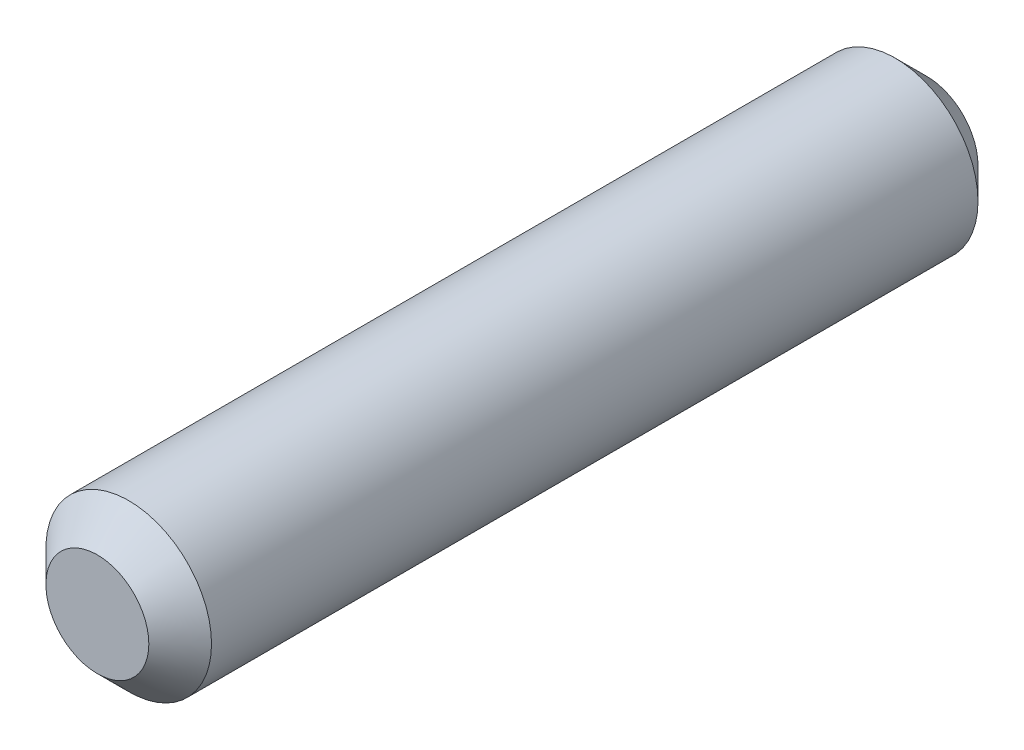
from build123d import *

# Parameters (mm, degrees)
SKETCH2_R           = 1.585
BOSS_EXTRUDE1_DEPTH = 7.935
CHAMFER1_SIZE       = 0.6


with BuildPart() as part:
    # Sketch2 → Boss-Extrude1 (new body, symmetric)
    with BuildSketch(Plane.XY):
        Circle(SKETCH2_R)
    extrude(amount=BOSS_EXTRUDE1_DEPTH, both=True)

    # Chamfer1
    chamfer1_edges = [part.edges().sort_by_distance(p)[0] for p in [
        (-1.585, 0, -7.935),
        (-1.585, 0, 7.935),
    ]]
    chamfer(chamfer1_edges, length=CHAMFER1_SIZE)


solid = part.part
